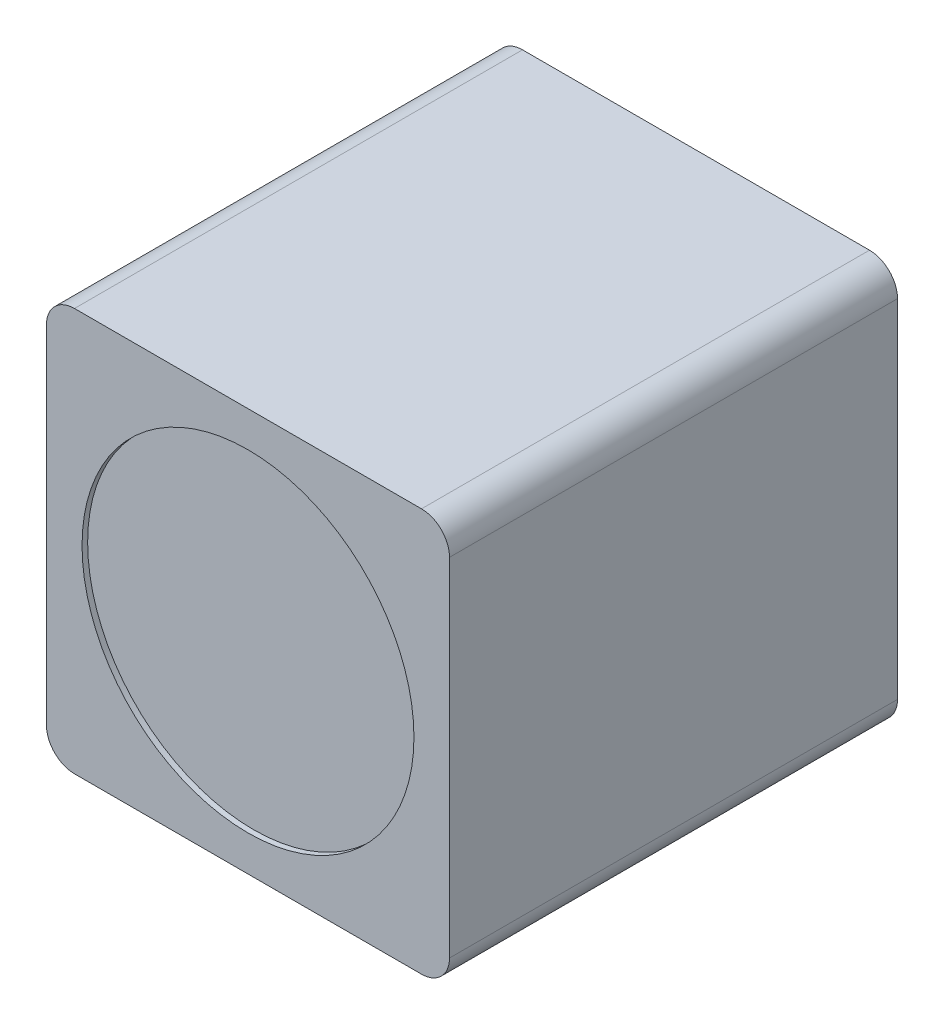
from build123d import *

# Parameters (mm, degrees)
SKETCH1_W           = 14.393333334
SKETCH1_H           = 14.393333333
BOSS_EXTRUDE1_DEPTH = 16
FILLET1_R           = 1
SKETCH2_R           = 5.926666667
CUT_EXTRUDE1_DEPTH  = 0.2


with BuildPart() as part:
    # Sketch1 → Boss-Extrude1 (new body)
    with BuildSketch(Plane.XY):
        with Locations((-166.361835023, 44.90232352)):
            Rectangle(SKETCH1_W, SKETCH1_H)
    extrude(amount=BOSS_EXTRUDE1_DEPTH)

    # Fillet1
    fillet1_edges = [part.edges().sort_by_distance(p)[0] for p in [
        (-159.165168356, 37.705656853, 8),
        (-173.55850169, 37.705656853, 8),
        (-173.55850169, 52.098990186, 8),
        (-159.165168356, 52.098990186, 8),
    ]]
    fillet(fillet1_edges, radius=FILLET1_R)

    # Sketch2 → Cut-Extrude1 (cut)
    with BuildSketch(Plane.XY.offset(16)):
        with Locations((-166.361835023, 44.902323519)):
            Circle(SKETCH2_R)
    extrude(amount=-CUT_EXTRUDE1_DEPTH, mode=Mode.SUBTRACT)


solid = part.part
